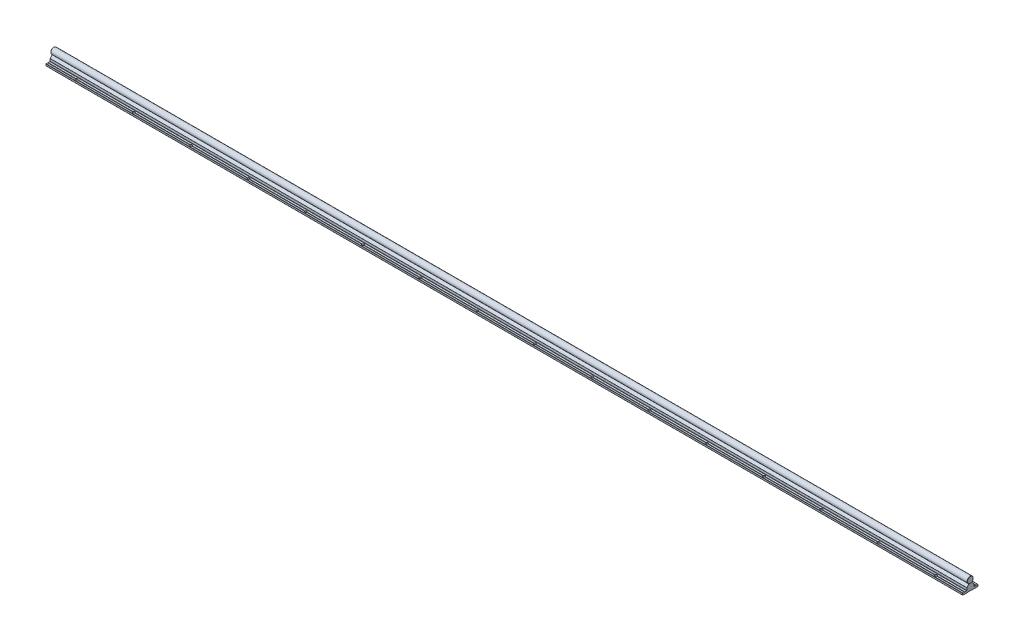
from build123d import *

# Parameters (mm, degrees)
EXTRUDE_9457_DEPTH       = 1500
SKETCH_1_3_R             = 8
EXTRUDE_9586_DEPTH       = 1500
FILLET_4_R               = 0.2
SKETCH_2_R               = 2.75
CUT_EXTRUDE_1_DEPTH      = 6
PATTERN_LINEAR_1_COUNT   = 20
PATTERN_LINEAR_1_PITCH   = 150
PATTERN_LINEAR_2_COUNT   = 20
PATTERN_LINEAR_2_PITCH   = 150
FILLET_1_R               = 0.3
CUT_EXTRUDE_2_DEPTH      = 3
FILLET_2_R               = 0.3
PATTERN_LINEAR_3_COUNT   = 20
PATTERN_LINEAR_3_PITCH   = 150
CHAMFER_1_SIZE           = 0.5
FILLET_3_R               = 0.5
FILLET_5_R               = 0.2
FILLET_6_R               = 0.1
FILLET_7_R               = 0.1
SKETCH_7_W               = 3500
SKETCH_7_H               = 1500
SKETCH_7_W_2             = 2400
SKETCH_7_H_2             = 1000
CUT_EXTRUDE_3_DEPTH      = 9.0000001
CUT_EXTRUDE_3_DEPTH_BACK = 26.0000001
CHAMFER_2_SIZE           = 0.5


with BuildPart() as part:
    # Sketch 1 → Extrude 9457 (new body, symmetric)
    with BuildSketch(Plane(origin=(0, 0, 0), x_dir=(0, 0, -1), z_dir=(1, 0, 0))):
        Polygon((-20, -25), (-4.75, -25), (-4.75, -24.4), (4.75, -24.4), (4.75, -25), (20, -25), (20, -20), (15.5, -20), (15, -20.5), (14.5, -20), (9.25, -20), (9.25, -13.3), (9.110116754, -13.3), (4, -7.21), (3.8, -7.21), (2.309327518, -7.65943904), (0, -8.355703281), (-2.309327444, -7.659439063), (-3.8, -7.21), (-4, -7.21), (-9.110116754, -13.3), (-9.25, -13.3), (-9.25, -20), (-14.5, -20), (-15, -20.5), (-15.5, -20), (-20, -20), align=None)
    extrude(amount=EXTRUDE_9457_DEPTH, both=True)

    # Fillet 4
    fillet_4_edges = [part.edges().sort_by_distance(p)[0] for p in [
        (0, -20, -15.5),
        (0, -24.4, -4.75),
        (0, -24.4, 4.75),
        (0, -20, 15.5),
        (0, -20, 14.5),
        (0, -8.355703281, 0),
        (0, -20, -14.5),
    ]]
    fillet(fillet_4_edges, radius=FILLET_4_R)

    # Sketch 2 → Cut-Extrude 1 (cut, through all)
    with BuildSketch(Plane(origin=(0, -20, 0), x_dir=(1, 0, 0), z_dir=(0, 1, 0))):
        with Locations((-1425, -15)):
            Circle(SKETCH_2_R)
        with Locations((-1425, 15)):
            Circle(SKETCH_2_R)
        with Locations((-1275, -15)):
            Circle(SKETCH_2_R)
        with Locations((-1275, 15)):
            Circle(SKETCH_2_R)
        with Locations((-1125, -15)):
            Circle(SKETCH_2_R)
        with Locations((-1125, 15)):
            Circle(SKETCH_2_R)
        with Locations((-975, -15)):
            Circle(SKETCH_2_R)
        with Locations((-975, 15)):
            Circle(SKETCH_2_R)
        with Locations((-825, -15)):
            Circle(SKETCH_2_R)
        with Locations((-825, 15)):
            Circle(SKETCH_2_R)
        with Locations((-675, -15)):
            Circle(SKETCH_2_R)
        with Locations((-675, 15)):
            Circle(SKETCH_2_R)
        with Locations((-525, -15)):
            Circle(SKETCH_2_R)
        with Locations((-525, 15)):
            Circle(SKETCH_2_R)
        with Locations((-375, -15)):
            Circle(SKETCH_2_R)
        with Locations((-375, 15)):
            Circle(SKETCH_2_R)
        with Locations((-225, -15)):
            Circle(SKETCH_2_R)
        with Locations((-225, 15)):
            Circle(SKETCH_2_R)
        with Locations((-75, -15)):
            Circle(SKETCH_2_R)
        with Locations((-75, 15)):
            Circle(SKETCH_2_R)
        with Locations((75, -15)):
            Circle(SKETCH_2_R)
        with Locations((75, 15)):
            Circle(SKETCH_2_R)
        with Locations((225, -15)):
            Circle(SKETCH_2_R)
        with Locations((225, 15)):
            Circle(SKETCH_2_R)
        with Locations((375, -15)):
            Circle(SKETCH_2_R)
        with Locations((375, 15)):
            Circle(SKETCH_2_R)
        with Locations((525, -15)):
            Circle(SKETCH_2_R)
        with Locations((525, 15)):
            Circle(SKETCH_2_R)
        with Locations((675, -15)):
            Circle(SKETCH_2_R)
        with Locations((675, 15)):
            Circle(SKETCH_2_R)
        with Locations((825, -15)):
            Circle(SKETCH_2_R)
        with Locations((825, 15)):
            Circle(SKETCH_2_R)
        with Locations((975, -15)):
            Circle(SKETCH_2_R)
        with Locations((975, 15)):
            Circle(SKETCH_2_R)
        with Locations((1125, -15)):
            Circle(SKETCH_2_R)
        with Locations((1125, 15)):
            Circle(SKETCH_2_R)
        with Locations((1275, -15)):
            Circle(SKETCH_2_R)
        with Locations((1275, 15)):
            Circle(SKETCH_2_R)
        with Locations((1425, -15)):
            Circle(SKETCH_2_R)
        with Locations((1425, 15)):
            Circle(SKETCH_2_R)
    extrude(amount=-CUT_EXTRUDE_1_DEPTH, mode=Mode.SUBTRACT)

    # Sketch 3 → Cut-Revolve 1 (revolve, cut)
    with BuildSketch(Plane.XY):
        Polygon((-1425, 0), (-1427.2, -1.270170592), (-1427.2, -7.5), (-1427.75, -7.5), (-1427.75, -19), (-1429.75, -19), (-1429.75, -24.4), (-1425, -24.4), align=None)
    cut_revolve_1 = revolve(axis=Axis((-1425, 56.434869358, 0), (0, -1, 0)), mode=Mode.SUBTRACT)

    # Pattern Linear 1: Cut-Revolve 1 ×20
    with Locations(*[(i * PATTERN_LINEAR_1_PITCH, 0, 0) for i in range(1, PATTERN_LINEAR_1_COUNT)]):
        add(cut_revolve_1, mode=Mode.SUBTRACT)

    # Fillet 3
    fillet_3_edges = [part.edges().sort_by_distance(p)[0] for p in [
        (0, -20, -9.25),
        (0, -20, -20),
        (0, -25, -20),
        (0, -25, -4.75),
        (0, -25, 4.75),
        (0, -20, 9.25),
        (0, -25, 20),
        (0, -20, 20),
    ]]
    fillet(fillet_3_edges, radius=FILLET_3_R)

    # Fillet 5
    fillet_5_edges = [part.edges().sort_by_distance(p)[0] for p in [
        (0, -7.21, 4),
        (0, -7.21, 3.8),
        (0, -7.21, -3.8),
        (0, -7.21, -4),
    ]]
    fillet(fillet_5_edges, radius=FILLET_5_R)

    # Fillet 6
    fillet_6_edges = [part.edges().sort_by_distance(p)[0] for p in [
        (0, -13.3, 9.25),
        (0, -13.3, -9.25),
    ]]
    fillet(fillet_6_edges, radius=FILLET_6_R)

    # Fillet 7
    fillet_7_edges = [part.edges().sort_by_distance(p)[0] for p in [
        (0, -13.3, 9.110116754),
        (0, -13.3, -9.110116754),
    ]]
    fillet(fillet_7_edges, radius=FILLET_7_R)


with BuildPart() as body_2:
    # Sketch 1_3 → Extrude 9586 (new body, symmetric)
    with BuildSketch(Plane(origin=(0, 0, 0), x_dir=(0, 0, -1), z_dir=(1, 0, 0))):
        Circle(SKETCH_1_3_R)
    extrude(amount=EXTRUDE_9586_DEPTH, both=True)

    # Sketch 4 → Cut-Revolve 2 (revolve, cut)
    with BuildSketch(Plane.XY):
        Polygon((-1425, -10), (-1427.2, -10), (-1427.2, -1.270170592), (-1425, 0), align=None)
    cut_revolve_2 = revolve(axis=Axis((-1425, 39.840222878, 0), (0, -1, 0)), mode=Mode.SUBTRACT)

    # Pattern Linear 2: Cut-Revolve 2 ×20
    with Locations(*[(i * PATTERN_LINEAR_2_PITCH, 0, 0) for i in range(1, PATTERN_LINEAR_2_COUNT)]):
        add(cut_revolve_2, mode=Mode.SUBTRACT)

    # Chamfer 1
    chamfer_1_edges = [body_2.edges().sort_by_distance(p)[0] for p in [
        (-1500, 0, 8),
        (1500, 0, 8),
    ]]
    chamfer(chamfer_1_edges, length=CHAMFER_1_SIZE)


with BuildPart() as body_3:
    # Sketch 5 → Revolve 1 (revolve)
    with BuildSketch(Plane.XY):
        Polygon((-1425, -24), (-1429.5, -24), (-1429.5, -19), (-1427.5, -19), (-1427.5, -2.461880215), (-1426.7, -2), (-1425, -2), align=None)
    revolve(axis=Axis((-1425, 35.529626596, 0), (0, -1, 0)))

    # Fillet 1
    fillet_1_edges = [body_3.edges().sort_by_distance(p)[0] for p in [
        (-1420.5, -19, 0),
    ]]
    fillet(fillet_1_edges, radius=FILLET_1_R)

    # Sketch 6 → Cut-Extrude 2 (cut)
    with BuildSketch(Plane.XZ.offset(24)):
        Polygon((-1423.25, -1.010362971), (-1423.25, 1.010362971), (-1425, 2.020725942), (-1426.75, 1.010362971), (-1426.75, -1.010362971), (-1425, -2.020725942), align=None)
    extrude(amount=-CUT_EXTRUDE_2_DEPTH, mode=Mode.SUBTRACT)

    # Fillet 2
    fillet_2_edges = [body_3.edges().sort_by_distance(p)[0] for p in [
        (-1424.125, -24, -1.515544457),
        (-1423.25, -24, 0),
        (-1424.125, -24, 1.515544457),
        (-1425.875, -24, 1.515544457),
        (-1426.75, -24, 0),
        (-1425.875, -24, -1.515544457),
        (-1420.5, -24, 0),
    ]]
    fillet(fillet_2_edges, radius=FILLET_2_R)


with BuildPart() as pattern_linear_3_1:
    # Pattern Linear 3: pattern copy
    add(body_3.part.moved(Location(Vector(1, 0, 0) * (1 * PATTERN_LINEAR_3_PITCH))))


with BuildPart() as pattern_linear_3_2:
    # Pattern Linear 3: pattern copy
    add(body_3.part.moved(Location(Vector(1, 0, 0) * (2 * PATTERN_LINEAR_3_PITCH))))


with BuildPart() as pattern_linear_3_3:
    # Pattern Linear 3: pattern copy
    add(body_3.part.moved(Location(Vector(1, 0, 0) * (3 * PATTERN_LINEAR_3_PITCH))))


with BuildPart() as pattern_linear_3_4:
    # Pattern Linear 3: pattern copy
    add(body_3.part.moved(Location(Vector(1, 0, 0) * (4 * PATTERN_LINEAR_3_PITCH))))


with BuildPart() as pattern_linear_3_5:
    # Pattern Linear 3: pattern copy
    add(body_3.part.moved(Location(Vector(1, 0, 0) * (5 * PATTERN_LINEAR_3_PITCH))))


with BuildPart() as pattern_linear_3_6:
    # Pattern Linear 3: pattern copy
    add(body_3.part.moved(Location(Vector(1, 0, 0) * (6 * PATTERN_LINEAR_3_PITCH))))


with BuildPart() as pattern_linear_3_7:
    # Pattern Linear 3: pattern copy
    add(body_3.part.moved(Location(Vector(1, 0, 0) * (7 * PATTERN_LINEAR_3_PITCH))))


with BuildPart() as pattern_linear_3_8:
    # Pattern Linear 3: pattern copy
    add(body_3.part.moved(Location(Vector(1, 0, 0) * (8 * PATTERN_LINEAR_3_PITCH))))


with BuildPart() as pattern_linear_3_9:
    # Pattern Linear 3: pattern copy
    add(body_3.part.moved(Location(Vector(1, 0, 0) * (9 * PATTERN_LINEAR_3_PITCH))))


with BuildPart() as pattern_linear_3_10:
    # Pattern Linear 3: pattern copy
    add(body_3.part.moved(Location(Vector(1, 0, 0) * (10 * PATTERN_LINEAR_3_PITCH))))


with BuildPart() as pattern_linear_3_11:
    # Pattern Linear 3: pattern copy
    add(body_3.part.moved(Location(Vector(1, 0, 0) * (11 * PATTERN_LINEAR_3_PITCH))))


with BuildPart() as pattern_linear_3_12:
    # Pattern Linear 3: pattern copy
    add(body_3.part.moved(Location(Vector(1, 0, 0) * (12 * PATTERN_LINEAR_3_PITCH))))


with BuildPart() as pattern_linear_3_13:
    # Pattern Linear 3: pattern copy
    add(body_3.part.moved(Location(Vector(1, 0, 0) * (13 * PATTERN_LINEAR_3_PITCH))))


with BuildPart() as pattern_linear_3_14:
    # Pattern Linear 3: pattern copy
    add(body_3.part.moved(Location(Vector(1, 0, 0) * (14 * PATTERN_LINEAR_3_PITCH))))


with BuildPart() as pattern_linear_3_15:
    # Pattern Linear 3: pattern copy
    add(body_3.part.moved(Location(Vector(1, 0, 0) * (15 * PATTERN_LINEAR_3_PITCH))))


with BuildPart() as pattern_linear_3_16:
    # Pattern Linear 3: pattern copy
    add(body_3.part.moved(Location(Vector(1, 0, 0) * (16 * PATTERN_LINEAR_3_PITCH))))


with BuildPart() as pattern_linear_3_17:
    # Pattern Linear 3: pattern copy
    add(body_3.part.moved(Location(Vector(1, 0, 0) * (17 * PATTERN_LINEAR_3_PITCH))))


with BuildPart() as pattern_linear_3_18:
    # Pattern Linear 3: pattern copy
    add(body_3.part.moved(Location(Vector(1, 0, 0) * (18 * PATTERN_LINEAR_3_PITCH))))


with BuildPart() as pattern_linear_3_19:
    # Pattern Linear 3: pattern copy
    add(body_3.part.moved(Location(Vector(1, 0, 0) * (19 * PATTERN_LINEAR_3_PITCH))))


with BuildPart() as cut_extrude_3_tool:
    # Sketch 7 → Cut-Extrude 3 (new body, two sides)
    with BuildSketch(Plane(origin=(0, 0, 0), x_dir=(1, 0, 0), z_dir=(0, 1, 0))) as cut_extrude_3_sk:
        Rectangle(SKETCH_7_W, SKETCH_7_H)
        Rectangle(SKETCH_7_W_2, SKETCH_7_H_2, mode=Mode.SUBTRACT)
    extrude(amount=CUT_EXTRUDE_3_DEPTH)
    extrude(cut_extrude_3_sk.sketch, amount=-CUT_EXTRUDE_3_DEPTH_BACK)


with BuildPart() as part_1:
    add(part.part)

    # Cut-Extrude 3: cut by cut_extrude_3_tool
    add(cut_extrude_3_tool.part, mode=Mode.SUBTRACT)


with BuildPart() as body_2_1:
    add(body_2.part)

    # Cut-Extrude 3: cut by cut_extrude_3_tool
    add(cut_extrude_3_tool.part, mode=Mode.SUBTRACT)

    # Chamfer 2
    chamfer_2_edges = [body_2_1.edges().sort_by_distance(p)[0] for p in [
        (-1200, 0, 8),
        (1200, 0, 8),
    ]]
    chamfer(chamfer_2_edges, length=CHAMFER_2_SIZE)


with BuildPart() as body_3_1:
    add(body_3.part)

    # Cut-Extrude 3: cut by cut_extrude_3_tool
    add(cut_extrude_3_tool.part, mode=Mode.SUBTRACT)


with BuildPart() as pattern_linear_3_1_1:
    add(pattern_linear_3_1.part)

    # Cut-Extrude 3: cut by cut_extrude_3_tool
    add(cut_extrude_3_tool.part, mode=Mode.SUBTRACT)


with BuildPart() as pattern_linear_3_18_1:
    add(pattern_linear_3_18.part)

    # Cut-Extrude 3: cut by cut_extrude_3_tool
    add(cut_extrude_3_tool.part, mode=Mode.SUBTRACT)


with BuildPart() as pattern_linear_3_19_1:
    add(pattern_linear_3_19.part)

    # Cut-Extrude 3: cut by cut_extrude_3_tool
    add(cut_extrude_3_tool.part, mode=Mode.SUBTRACT)


solid = Compound([pattern_linear_3_2.part, pattern_linear_3_3.part, pattern_linear_3_4.part, pattern_linear_3_5.part, pattern_linear_3_6.part, pattern_linear_3_7.part, pattern_linear_3_8.part, pattern_linear_3_9.part, pattern_linear_3_10.part, pattern_linear_3_11.part, pattern_linear_3_12.part, pattern_linear_3_13.part, pattern_linear_3_14.part, pattern_linear_3_15.part, pattern_linear_3_16.part, pattern_linear_3_17.part, part_1.part, body_2_1.part])
